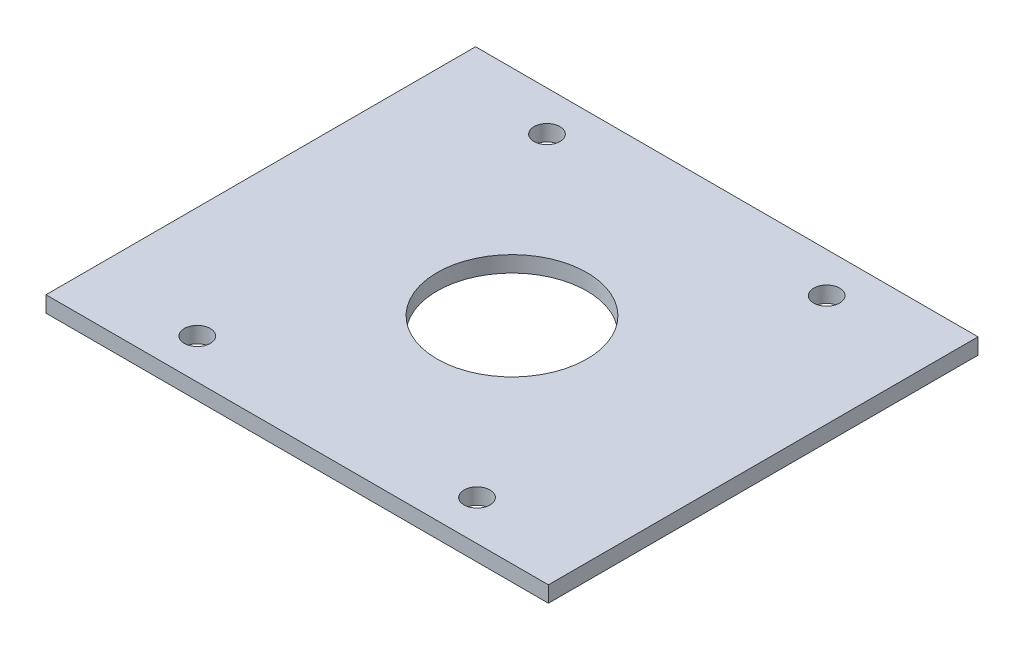
from build123d import *

# Parameters (mm, degrees)
SKETCH1_W           = 50.292
SKETCH1_H           = 43
SKETCH1_R           = 7.5
BOSS_EXTRUDE1_DEPTH = 1.6
SKETCH2_R           = 1.3
CUT_EXTRUDE3_DEPTH  = 2.6


with BuildPart() as part:
    # Sketch1 → Boss-Extrude1 (new body)
    with BuildSketch(Plane(origin=(0, 0, 0), x_dir=(1, 0, 0), z_dir=(0, 1, 0))):
        Rectangle(SKETCH1_W, SKETCH1_H)
        Circle(SKETCH1_R, mode=Mode.SUBTRACT)
    extrude(amount=BOSS_EXTRUDE1_DEPTH)

    # Sketch2 → Cut-Extrude3 (cut, through all)
    with BuildSketch(Plane(origin=(0, 0, 0), x_dir=(1, 0, 0), z_dir=(0, 1, 0))):
        with Locations((-14, 17.5)):
            Circle(SKETCH2_R)
        with Locations((14, 17.5)):
            Circle(SKETCH2_R)
        with Locations((14, -17.5)):
            Circle(SKETCH2_R)
        with Locations((-14, -17.5)):
            Circle(SKETCH2_R)
    extrude(amount=CUT_EXTRUDE3_DEPTH, mode=Mode.SUBTRACT)


solid = part.part
